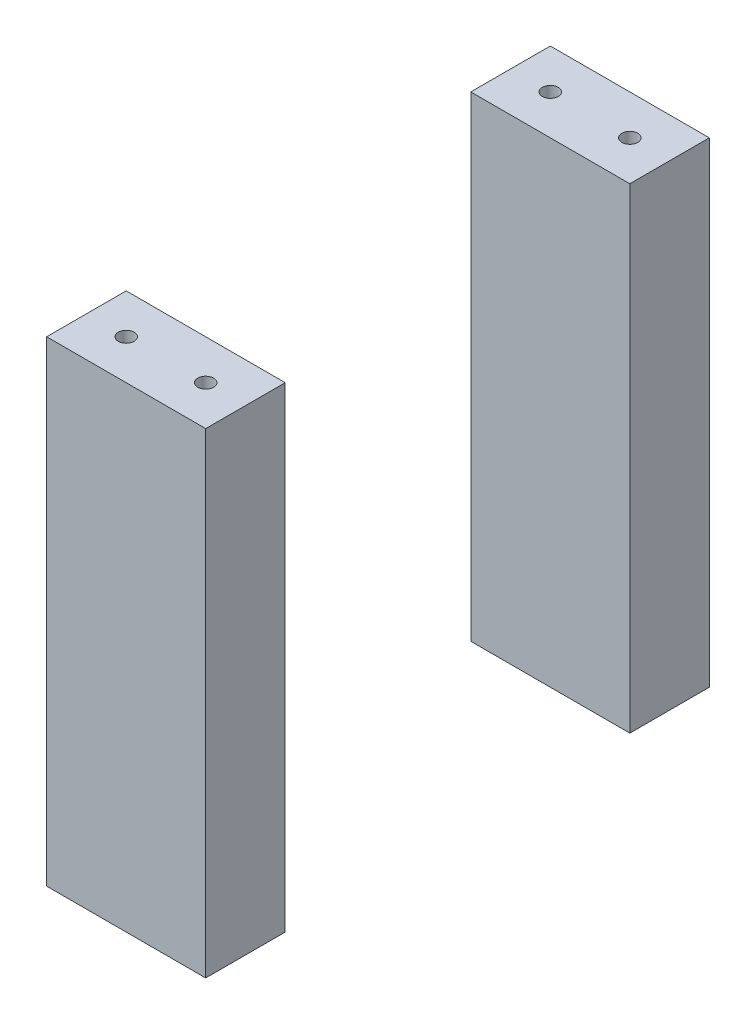
from build123d import *

# Parameters (mm, degrees)
SKIZZE4_W                              = 60
SKIZZE4_H                              = 30
SKIZZE4_R                              = 3
AUFSATZ_LINEAR_AUSTRAGEN1_DEPTH        = 163.5
AUFSATZ_LINEAR_AUSTRAGEN1_DEPTH_BACK   = 16
AUFSATZ_LINEAR_AUSTRAGEN1_2_DEPTH      = 163.5
AUFSATZ_LINEAR_AUSTRAGEN1_2_DEPTH_BACK = 16


with BuildPart() as part:
    # Skizze4 → Aufsatz-Linear austragen1 (new body, two sides)
    with BuildSketch(Plane(origin=(0, 0, 0), x_dir=(1, 0, 0), z_dir=(0, 1, 0))) as aufsatz_linear_austragen1_sk:
        with Locations((0, -110)):
            Rectangle(SKIZZE4_W, SKIZZE4_H)
        with Locations((-15, -110)):
            Circle(SKIZZE4_R, mode=Mode.SUBTRACT)
        with Locations((15, -110)):
            Circle(SKIZZE4_R, mode=Mode.SUBTRACT)
    extrude(amount=AUFSATZ_LINEAR_AUSTRAGEN1_DEPTH)
    extrude(aufsatz_linear_austragen1_sk.sketch, amount=-AUFSATZ_LINEAR_AUSTRAGEN1_DEPTH_BACK)


with BuildPart() as body_2:
    # Skizze4 → Aufsatz-Linear austragen1 2 (new body, two sides)
    with BuildSketch(Plane(origin=(0, 0, 0), x_dir=(1, 0, 0), z_dir=(0, 1, 0))) as aufsatz_linear_austragen1_2_sk:
        with Locations((0, -270)):
            Rectangle(SKIZZE4_W, SKIZZE4_H)
        with Locations((15, -270)):
            Circle(SKIZZE4_R, mode=Mode.SUBTRACT)
        with Locations((-15, -270)):
            Circle(SKIZZE4_R, mode=Mode.SUBTRACT)
    extrude(amount=AUFSATZ_LINEAR_AUSTRAGEN1_2_DEPTH)
    extrude(aufsatz_linear_austragen1_2_sk.sketch, amount=-AUFSATZ_LINEAR_AUSTRAGEN1_2_DEPTH_BACK)


solid = Compound([part.part, body_2.part])
